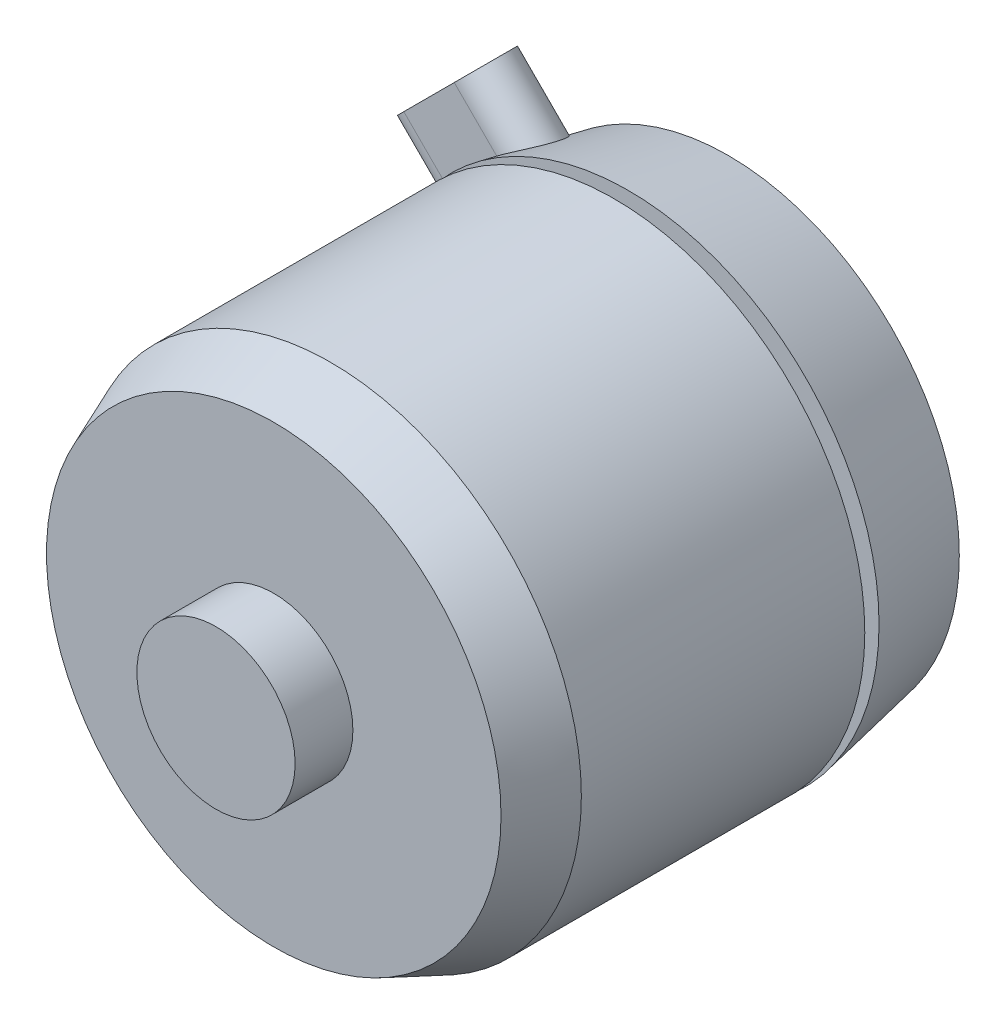
from build123d import *

# Parameters (mm, degrees)
SKETCH2_R           = 1.29
CUT_EXTRUDE1_DEPTH  = 7
BOSS_EXTRUDE1_DEPTH = 3.81


with BuildPart() as part:
    # Sketch1 → Revolve1 (revolve)
    with BuildSketch(Plane(origin=(0, 0, 0), x_dir=(0, 0, -1), z_dir=(1, 0, 0))):
        Polygon((0, 0), (0, 5.5499), (4.0513, 5.5499), (4.0513, 15.94), (8.0513, 17.575), (27.9313, 17.575), (27.9313, 6.019833944), (28.9313, 6.019833944), (28.9313, 17.575), (35.9313, 16.205000102), (35.9313, 4.73075), (36.5155, 4.73075), (36.5155, 2.4511), (37.4807, 2.4511), (37.4807, 0), align=None)
    revolve(axis=Axis((0, 0, 1000), (0, 0, -1)))

    # Sketch2 → Cut-Extrude1 (cut)
    with BuildSketch(Plane(origin=(0, 0, -35.9313), x_dir=(-1, 0, 0), z_dir=(0, 0, -1))):
        with Locations((-12.57, 0)):
            Circle(SKETCH2_R)
        with Locations((0, 9.545)):
            Circle(SKETCH2_R)
        with Locations((12.57, 0)):
            Circle(SKETCH2_R)
        with Locations((0, -9.545)):
            Circle(SKETCH2_R)
    extrude(amount=-CUT_EXTRUDE1_DEPTH, mode=Mode.SUBTRACT)

    # Sketch3 → Boss-Extrude1 (add, symmetric)
    with BuildSketch(Plane(origin=(-12.427401679, 12.427401679, 0), x_dir=(0, 0, -1), z_dir=(-0.707106781, 0.707106781, 0))):
        with BuildLine():
            Line((34.0517, 2.5019), (34.0517, -2.5019))
            ThreePointArc((34.0517, -2.5019), (32.0578, -4.4958), (30.0639, -2.5019))
            Line((30.0639, -2.5019), (30.0639, 2.5019))
            ThreePointArc((30.0639, 2.5019), (32.0578, 4.4958), (34.0517, 2.5019))
        make_face()
    extrude(amount=BOSS_EXTRUDE1_DEPTH, both=True)


solid = part.part
